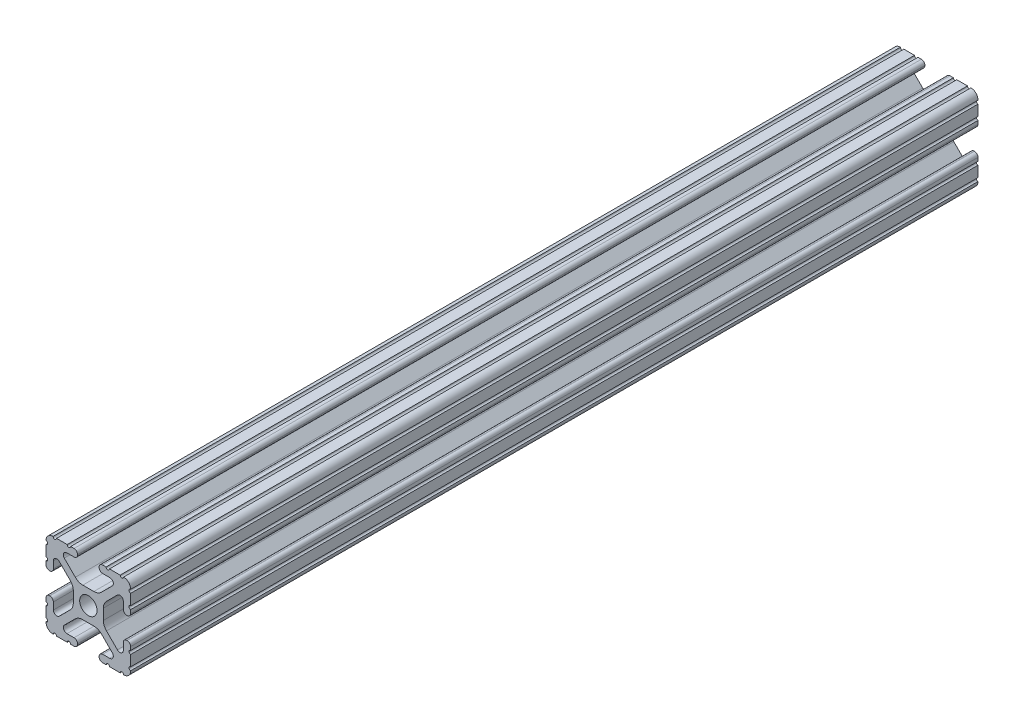
from build123d import *

# Parameters (mm, degrees)
SKETCH1_R           = 2.6035
BOSS_EXTRUDE1_DEPTH = 254.2


with BuildPart() as part:
    # Sketch1 → Boss-Extrude1 (new body)
    with BuildSketch(Plane.XY):
        with BuildLine():
            Line((-7.179650497, -8.645192506), (-3.952270251, -5.423690499))
            ThreePointArc((-3.952270251, -5.423690499), (-2.922936451, -4.736929036), (-1.709253557, -4.4958))
            Line((-1.709253557, -4.4958), (1.709253557, -4.4958))
            ThreePointArc((1.709253557, -4.4958), (2.922936451, -4.736929036), (3.952270251, -5.423690499))
            Line((3.952270251, -5.423690499), (7.179650497, -8.645192506))
            ThreePointArc((7.179650497, -8.645192506), (7.41473083, -9.822813117), (6.416408329, -10.4902))
            Line((6.416408329, -10.4902), (4.287512407, -10.4902))
            ThreePointArc((4.287512407, -10.4902), (3.54574862, -10.79744862), (3.2385, -11.539212407))
            Line((3.2385, -11.539212407), (3.2385, -11.650987593))
            ThreePointArc((3.2385, -11.650987593), (3.54574862, -12.39275138), (4.287512407, -12.7))
            Line((4.287512407, -12.7), (5.317126718, -12.7))
            ThreePointArc((5.317126718, -12.7), (5.825126718, -12.192), (6.333126718, -12.7))
            Line((6.333126718, -12.7), (9.550443118, -12.7))
            ThreePointArc((9.550443118, -12.7), (10.058366869, -12.192000006), (10.566443095, -12.699847501))
            ThreePointArc((10.566443095, -12.699847501), (12.082537762, -12.08250727), (12.699846982, -10.566399977))
            ThreePointArc((12.699846982, -10.566399977), (12.192000006, -10.058323491), (12.7, -9.5504))
            Line((12.7, -9.5504), (12.7, -6.3330836))
            ThreePointArc((12.7, -6.3330836), (12.192, -5.8250836), (12.7, -5.3170836))
            Line((12.7, -5.3170836), (12.7, -4.287469289))
            ThreePointArc((12.7, -4.287469289), (12.39275138, -3.545705502), (11.650987593, -3.238456882))
            Line((11.650987593, -3.238456882), (11.539212407, -3.238456882))
            ThreePointArc((11.539212407, -3.238456882), (10.79744862, -3.545705502), (10.4902, -4.287469289))
            Line((10.4902, -4.287469289), (10.4902, -6.402089023))
            ThreePointArc((10.4902, -6.402089023), (9.856505071, -7.351067942), (8.737131347, -7.129408934))
            Line((8.737131347, -7.129408934), (5.441005833, -3.840816462))
            ThreePointArc((5.441005833, -3.840816462), (4.750877967, -2.809883091), (4.5085, -1.593185507))
            Line((4.5085, -1.593185507), (4.5085, 1.593185507))
            ThreePointArc((4.5085, 1.593185507), (4.750877967, 2.809883091), (5.441005833, 3.840816462))
            Line((5.441005833, 3.840816462), (8.737131347, 7.129408934))
            ThreePointArc((8.737131347, 7.129408934), (9.856505071, 7.351067942), (10.4902, 6.402089023))
            Line((10.4902, 6.402089023), (10.4902, 4.287469289))
            ThreePointArc((10.4902, 4.287469289), (10.79744862, 3.545705502), (11.539212407, 3.238456882))
            Line((11.539212407, 3.238456882), (11.650987593, 3.238456882))
            ThreePointArc((11.650987593, 3.238456882), (12.39275138, 3.545705502), (12.7, 4.287469289))
            Line((12.7, 4.287469289), (12.7, 5.3170836))
            ThreePointArc((12.7, 5.3170836), (12.192, 5.8250836), (12.7, 6.3330836))
            Line((12.7, 6.3330836), (12.7, 9.5504))
            ThreePointArc((12.7, 9.5504), (12.192000006, 10.058323491), (12.699846982, 10.566399977))
            ThreePointArc((12.699846982, 10.566399977), (12.082537762, 12.08250727), (10.566443095, 12.699847501))
            ThreePointArc((10.566443095, 12.699847501), (10.058366869, 12.192000006), (9.550443118, 12.7))
            Line((9.550443118, 12.7), (6.333126718, 12.7))
            ThreePointArc((6.333126718, 12.7), (5.825126718, 12.192), (5.317126718, 12.7))
            Line((5.317126718, 12.7), (4.287512407, 12.7))
            ThreePointArc((4.287512407, 12.7), (3.54574862, 12.39275138), (3.2385, 11.650987593))
            Line((3.2385, 11.650987593), (3.2385, 11.539212407))
            ThreePointArc((3.2385, 11.539212407), (3.54574862, 10.79744862), (4.287512407, 10.4902))
            Line((4.287512407, 10.4902), (6.476788598, 10.4902))
            ThreePointArc((6.476788598, 10.4902), (7.432222385, 9.85140422), (7.207036008, 8.724370562))
            Line((7.207036008, 8.724370562), (3.898272566, 5.423169045))
            ThreePointArc((3.898272566, 5.423169045), (2.869120213, 4.736787962), (1.655778399, 4.4958))
            Line((1.655778399, 4.4958), (-1.655778399, 4.4958))
            ThreePointArc((-1.655778399, 4.4958), (-2.869120213, 4.736787962), (-3.898272566, 5.423169045))
            Line((-3.898272566, 5.423169045), (-7.207036008, 8.724370562))
            ThreePointArc((-7.207036008, 8.724370562), (-7.432222385, 9.85140422), (-6.476788598, 10.4902))
            Line((-6.476788598, 10.4902), (-4.287512407, 10.4902))
            ThreePointArc((-4.287512407, 10.4902), (-3.54574862, 10.79744862), (-3.2385, 11.539212407))
            Line((-3.2385, 11.539212407), (-3.2385, 11.650987593))
            ThreePointArc((-3.2385, 11.650987593), (-3.54574862, 12.39275138), (-4.287512407, 12.7))
            Line((-4.287512407, 12.7), (-5.317126718, 12.7))
            ThreePointArc((-5.317126718, 12.7), (-5.825126718, 12.192), (-6.333126718, 12.7))
            Line((-6.333126718, 12.7), (-9.550443118, 12.7))
            ThreePointArc((-9.550443118, 12.7), (-10.058366869, 12.192000006), (-10.566443095, 12.699847501))
            ThreePointArc((-10.566443095, 12.699847501), (-12.082537762, 12.08250727), (-12.699846982, 10.566399977))
            ThreePointArc((-12.699846982, 10.566399977), (-12.192000006, 10.058323491), (-12.7, 9.5504))
            Line((-12.7, 9.5504), (-12.7, 6.3330836))
            ThreePointArc((-12.7, 6.3330836), (-12.192, 5.8250836), (-12.7, 5.3170836))
            Line((-12.7, 5.3170836), (-12.7, 4.287469289))
            ThreePointArc((-12.7, 4.287469289), (-12.39275138, 3.545705502), (-11.650987593, 3.238456882))
            Line((-11.650987593, 3.238456882), (-11.539212407, 3.238456882))
            ThreePointArc((-11.539212407, 3.238456882), (-10.79744862, 3.545705502), (-10.4902, 4.287469289))
            Line((-10.4902, 4.287469289), (-10.4902, 6.402089023))
            ThreePointArc((-10.4902, 6.402089023), (-9.856505071, 7.351067942), (-8.737131347, 7.129408934))
            Line((-8.737131347, 7.129408934), (-5.441005833, 3.840816462))
            ThreePointArc((-5.441005833, 3.840816462), (-4.750877967, 2.809883091), (-4.5085, 1.593185507))
            Line((-4.5085, 1.593185507), (-4.5085, -1.593185507))
            ThreePointArc((-4.5085, -1.593185507), (-4.750877967, -2.809883091), (-5.441005833, -3.840816462))
            Line((-5.441005833, -3.840816462), (-8.737131347, -7.129408934))
            ThreePointArc((-8.737131347, -7.129408934), (-9.856505071, -7.351067942), (-10.4902, -6.402089023))
            Line((-10.4902, -6.402089023), (-10.4902, -4.287469289))
            ThreePointArc((-10.4902, -4.287469289), (-10.79744862, -3.545705502), (-11.539212407, -3.238456882))
            Line((-11.539212407, -3.238456882), (-11.650987593, -3.238456882))
            ThreePointArc((-11.650987593, -3.238456882), (-12.39275138, -3.545705502), (-12.7, -4.287469289))
            Line((-12.7, -4.287469289), (-12.7, -5.3170836))
            ThreePointArc((-12.7, -5.3170836), (-12.192, -5.8250836), (-12.7, -6.3330836))
            Line((-12.7, -6.3330836), (-12.7, -9.5504))
            ThreePointArc((-12.7, -9.5504), (-12.192000006, -10.058323491), (-12.699846982, -10.566399977))
            ThreePointArc((-12.699846982, -10.566399977), (-12.082537762, -12.08250727), (-10.566443095, -12.699847501))
            ThreePointArc((-10.566443095, -12.699847501), (-10.058366869, -12.192000006), (-9.550443118, -12.7))
            Line((-9.550443118, -12.7), (-6.333126718, -12.7))
            ThreePointArc((-6.333126718, -12.7), (-5.825126718, -12.192), (-5.317126718, -12.7))
            Line((-5.317126718, -12.7), (-4.287512407, -12.7))
            ThreePointArc((-4.287512407, -12.7), (-3.54574862, -12.39275138), (-3.2385, -11.650987593))
            Line((-3.2385, -11.650987593), (-3.2385, -11.539212407))
            ThreePointArc((-3.2385, -11.539212407), (-3.54574862, -10.79744862), (-4.287512407, -10.4902))
            Line((-4.287512407, -10.4902), (-6.416408329, -10.4902))
            ThreePointArc((-6.416408329, -10.4902), (-7.41473083, -9.822813117), (-7.179650497, -8.645192506))
        make_face()
        Circle(SKETCH1_R, mode=Mode.SUBTRACT)
    extrude(amount=BOSS_EXTRUDE1_DEPTH)


solid = part.part
